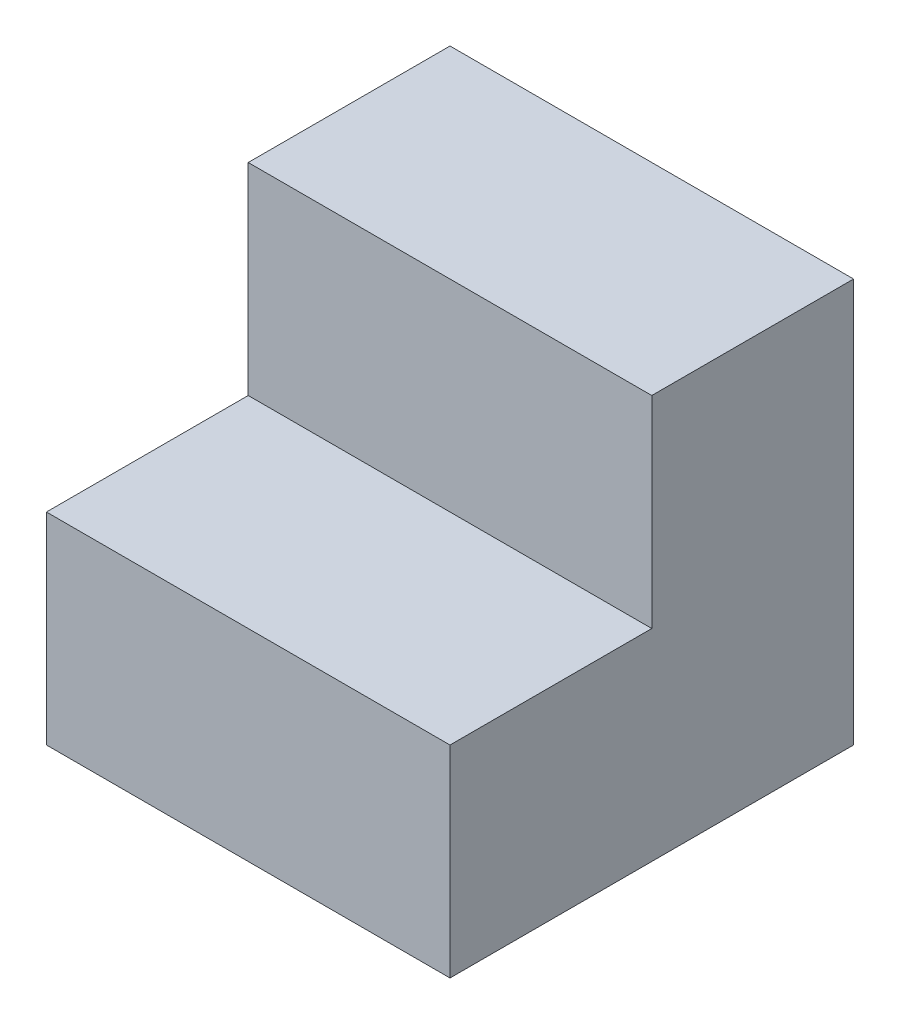
from build123d import *

# Parameters (mm, degrees)
BOSS_EXTRUDE1_DEPTH = 40


with BuildPart() as part:
    # Sketch2 → Boss-Extrude1 (new body, symmetric)
    with BuildSketch(Plane(origin=(0, 0, 0), x_dir=(0, 0, -1), z_dir=(1, 0, 0))):
        Polygon((0, 80), (0, 0), (-80, 0), (-80, 40), (-40, 40), (-40, 80), align=None)
    extrude(amount=BOSS_EXTRUDE1_DEPTH, both=True)


solid = part.part
